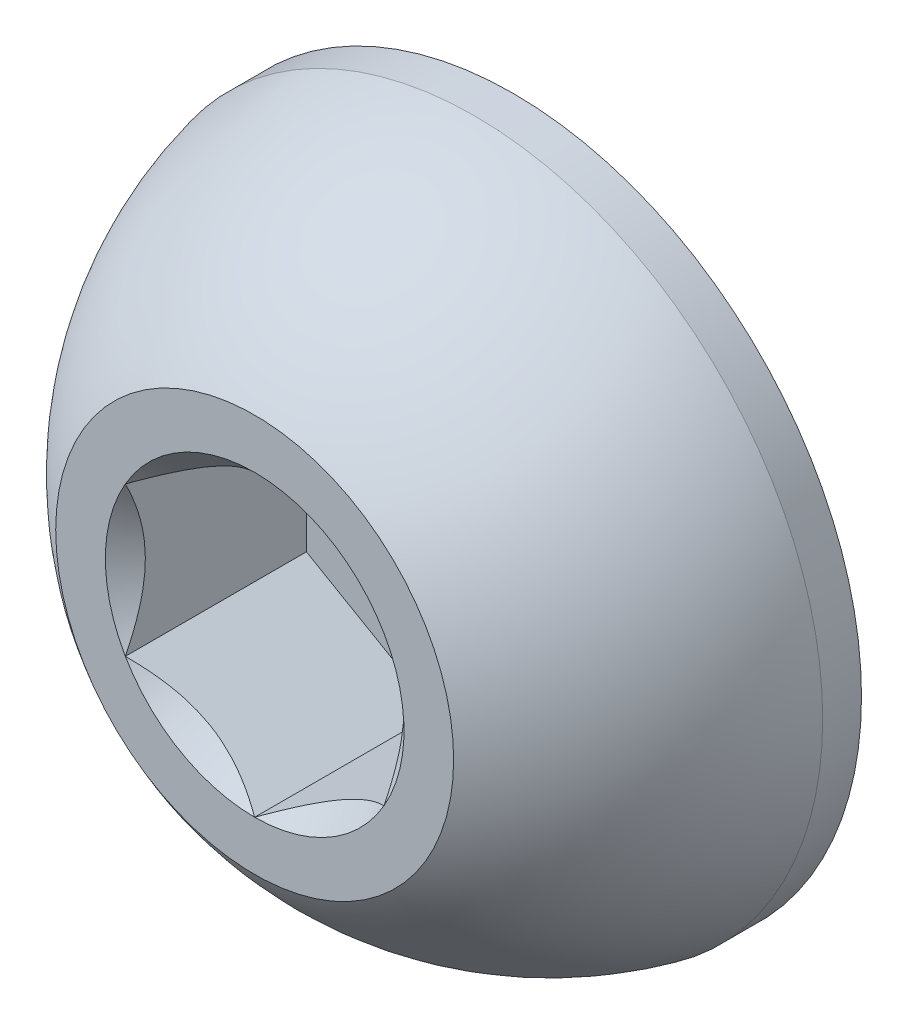
from build123d import *

# Parameters (mm, degrees)
REVOLVE2_ANGLE     = 360
CUT_EXTRUDE2_DEPTH = 0.91
SKETCH6_R          = 0.75055535
CUT_EXTRUDE3_DEPTH = 0.91
CUT_EXTRUDE3_DRAFT = -45


with BuildPart() as part:
    # Sketch7 → Revolve2 (revolve, symmetric)
    with BuildSketch(Plane(origin=(0, 0, 0), x_dir=(0, 0, -1), z_dir=(1, 0, 0))) as revolve2_sk:
        with BuildLine():
            Line((1.105, 1.75), (1.3, 1.75))
            Line((1.3, 1.75), (1.3, 0))
            Line((1.3, 0), (0, 0))
            Line((0, 0), (0, 1))
            ThreePointArc((0, 1), (0.479976957, 1.481850617), (1.105, 1.75))
        make_face()
    revolve(axis=Axis((0, 0, 0), (0, 0, -1)), revolution_arc=REVOLVE2_ANGLE / 2)
    revolve(revolve2_sk.sketch, axis=Axis((0, 0, 0), (0, 0, 1)), revolution_arc=REVOLVE2_ANGLE / 2)

    # Sketch5 → Cut-Extrude2 (cut)
    with BuildSketch(Plane.XY):
        Polygon((0.65, -0.375277675), (0.65, 0.375277675), (0, 0.75055535), (-0.65, 0.375277675), (-0.65, -0.375277675), (0, -0.75055535), align=None)
    extrude(amount=-CUT_EXTRUDE2_DEPTH, mode=Mode.SUBTRACT)


with BuildPart() as cut_extrude3_tool:
    # Sketch6 → Cut-Extrude3 (with draft: the straight prism first)
    with BuildSketch(Plane.XY):
        Circle(SKETCH6_R)
    extrude(amount=-CUT_EXTRUDE3_DEPTH)
    # Cut-Extrude3: the draft: its side faces are tilted about the plane it starts from
    cut_extrude3_sides = [cut_extrude3_tool.faces().sort_by_distance(p)[0] for p in [
        (-0.75055535, 0, -0.455),
    ]]
    draft(cut_extrude3_sides, Plane.XY, CUT_EXTRUDE3_DRAFT)


with BuildPart() as part_1:
    add(part.part)

    # Cut-Extrude3: cut by cut_extrude3_tool
    add(cut_extrude3_tool.part, mode=Mode.SUBTRACT)


solid = part_1.part
